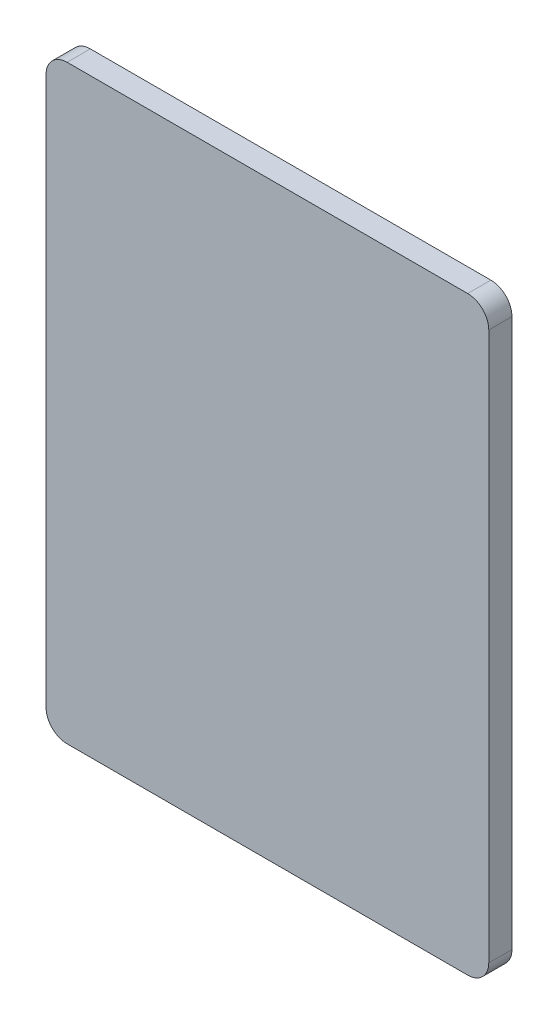
from build123d import *

# Parameters (mm, degrees)
SKETCH2_W           = 210
SKETCH2_H           = 280
BOSS_EXTRUDE1_DEPTH = 11
FILLET1_R           = 10


with BuildPart() as part:
    # Sketch2 → Boss-Extrude1 (new body)
    with BuildSketch(Plane.XY):
        Rectangle(SKETCH2_W, SKETCH2_H)
    extrude(amount=BOSS_EXTRUDE1_DEPTH)

    # Fillet1
    fillet1_edges = [part.edges().sort_by_distance(p)[0] for p in [
        (105, -140, 5.5),
        (-105, -140, 5.5),
        (-105, 140, 5.5),
        (105, 140, 5.5),
    ]]
    fillet(fillet1_edges, radius=FILLET1_R)


solid = part.part
